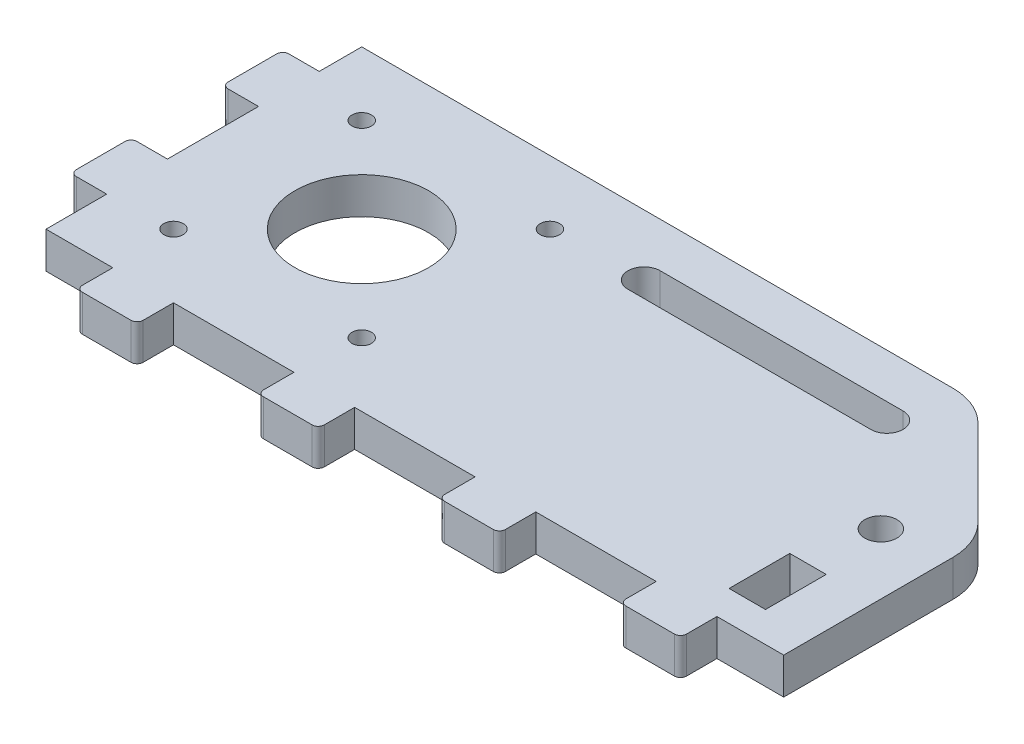
from build123d import *

# Parameters (mm, degrees)
SKETCH1_W               = 121.5
SKETCH1_H               = 52
BOSS_EXTRUDE1_DEPTH     = 6
CHAMFER1_SIZE           = 20
M5_CLEARANCE_HOLE1_D    = 5.3
CUT_EXTRUDE4_DEPTH      = 7
M3_CLEARANCE_HOLE1_D    = 3.2
SKETCH6_R               = 11
CUT_EXTRUDE3_DEPTH      = 7
SKETCH234_W             = 10
SKETCH234_H             = 6
BOSS_EXTRUDE234_DEPTH   = 6
FILLET134_R             = 1
SKETCH2341_W            = 10
SKETCH2341_H            = 6
BOSS_EXTRUDE2341_DEPTH  = 6
FILLET1341_R            = 1
SKETCH2342_W            = 10
SKETCH2342_H            = 6
BOSS_EXTRUDE2342_DEPTH  = 6
FILLET1342_R            = 1
SKETCH2343_W            = 10
SKETCH2343_H            = 6
BOSS_EXTRUDE2343_DEPTH  = 6
FILLET1343_R            = 1
SKETCH2345_W            = 10
SKETCH2345_H            = 6
BOSS_EXTRUDE2345_DEPTH  = 6
FILLET1345_R            = 1
SKETCH2346_W            = 10
SKETCH2346_H            = 6
BOSS_EXTRUDE2346_DEPTH  = 6
FILLET1346_R            = 1
FILLET1347_R            = 10
SKETCH62_W              = 10
SKETCH62_H              = 6
CUT_EXTRUDE1_DEPTH      = 4
CUT_EXTRUDE1_DEPTH_BACK = 4


with BuildPart() as part:
    # Sketch1 → Boss-Extrude1 (new body)
    with BuildSketch(Plane(origin=(0, 0, 0), x_dir=(1, 0, 0), z_dir=(0, 1, 0))):
        with Locations((60.75, 26)):
            Rectangle(SKETCH1_W, SKETCH1_H)
    extrude(amount=BOSS_EXTRUDE1_DEPTH)

    # Chamfer1
    chamfer1_edges = [part.edges().sort_by_distance(p)[0] for p in [
        (121.5, 3, -52),
    ]]
    chamfer(chamfer1_edges, length=CHAMFER1_SIZE)

    # M5 Clearance Hole1 (through all)
    with Locations(Plane(origin=(0, 6, 0), x_dir=(1, 0, 0), z_dir=(0, 1, 0))):
        with Locations((111.5, 26)):
            Hole(M5_CLEARANCE_HOLE1_D / 2)

    # Sketch7 → Cut-Extrude4 (cut, through all)
    with BuildSketch(Plane(origin=(0, 6, 0), x_dir=(1, 0, 0), z_dir=(0, 1, 0))):
        with BuildLine():
            Line((56.5, 44.65), (96.5, 44.65))
            ThreePointArc((96.5, 44.65), (99.15, 42), (96.5, 39.35))
            Line((96.5, 39.35), (56.5, 39.35))
            ThreePointArc((56.5, 39.35), (53.85, 42), (56.5, 44.65))
        make_face()
    extrude(amount=-CUT_EXTRUDE4_DEPTH, mode=Mode.SUBTRACT)

    # M3 Clearance Hole1 (through all)
    with Locations(Plane(origin=(26, 0, -26), x_dir=(0, 0, 1), z_dir=(0, -1, 0))):
        with Locations((15.5, -15.5), (-15.5, -15.5), (-15.5, 15.5), (15.5, 15.5)):
            Hole(M3_CLEARANCE_HOLE1_D / 2)

    # Sketch6 → Cut-Extrude3 (cut, through all)
    with BuildSketch(Plane(origin=(26, 0, -26), x_dir=(0, 0, -1), z_dir=(0, -1, 0))):
        Circle(SKETCH6_R)
    extrude(amount=-CUT_EXTRUDE3_DEPTH, mode=Mode.SUBTRACT)

    # Sketch234 → Boss-Extrude234 (add)
    with BuildSketch(Plane(origin=(16.767778608, 6, 0), x_dir=(-1, 0, 0), z_dir=(0, 0, 1))):
        with Locations((0.767778608, 3)):
            Rectangle(SKETCH234_W, SKETCH234_H)
    extrude(amount=BOSS_EXTRUDE234_DEPTH)

    # Fillet134
    fillet134_edges = [part.edges().sort_by_distance(p)[0] for p in [
        (21, 3, 6),
        (11, 3, 6),
    ]]
    fillet(fillet134_edges, radius=FILLET134_R)

    # Sketch2341 → Boss-Extrude2341 (add)
    with BuildSketch(Plane(origin=(46.601111941, 6, 0), x_dir=(-1, 0, 0), z_dir=(0, 0, 1))):
        with Locations((0.767778608, 3)):
            Rectangle(SKETCH2341_W, SKETCH2341_H)
    extrude(amount=BOSS_EXTRUDE2341_DEPTH)

    # Fillet1341
    fillet1341_edges = [part.edges().sort_by_distance(p)[0] for p in [
        (40.833333333, 3, 6),
        (50.833333333, 3, 6),
    ]]
    fillet(fillet1341_edges, radius=FILLET1341_R)

    # Sketch2342 → Boss-Extrude2342 (add)
    with BuildSketch(Plane(origin=(76.434445274, 6, 0), x_dir=(-1, 0, 0), z_dir=(0, 0, 1))):
        with Locations((0.767778608, 3)):
            Rectangle(SKETCH2342_W, SKETCH2342_H)
    extrude(amount=BOSS_EXTRUDE2342_DEPTH)

    # Fillet1342
    fillet1342_edges = [part.edges().sort_by_distance(p)[0] for p in [
        (70.666666667, 3, 6),
        (80.666666667, 3, 6),
    ]]
    fillet(fillet1342_edges, radius=FILLET1342_R)

    # Sketch2343 → Boss-Extrude2343 (add)
    with BuildSketch(Plane(origin=(106.267778608, 6, 0), x_dir=(-1, 0, 0), z_dir=(0, 0, 1))):
        with Locations((0.767778608, 3)):
            Rectangle(SKETCH2343_W, SKETCH2343_H)
    extrude(amount=BOSS_EXTRUDE2343_DEPTH)

    # Fillet1343
    fillet1343_edges = [part.edges().sort_by_distance(p)[0] for p in [
        (100.5, 3, 6),
        (110.5, 3, 6),
    ]]
    fillet(fillet1343_edges, radius=FILLET1343_R)

    # Sketch2345 → Boss-Extrude2345 (add)
    with BuildSketch(Plane(origin=(0, 0, -15.767778608), x_dir=(0, 0, 1), z_dir=(-1, 0, 0))):
        with Locations((0.767778608, 3)):
            Rectangle(SKETCH2345_W, SKETCH2345_H)
    extrude(amount=BOSS_EXTRUDE2345_DEPTH)

    # Fillet1345
    fillet1345_edges = [part.edges().sort_by_distance(p)[0] for p in [
        (-6, 3, -20),
        (-6, 3, -10),
    ]]
    fillet(fillet1345_edges, radius=FILLET1345_R)

    # Sketch2346 → Boss-Extrude2346 (add)
    with BuildSketch(Plane(origin=(0, 6, -39.232221392), x_dir=(0, 0, -1), z_dir=(-1, 0, 0))):
        with Locations((0.767778608, 3)):
            Rectangle(SKETCH2346_W, SKETCH2346_H)
    extrude(amount=BOSS_EXTRUDE2346_DEPTH)

    # Fillet1346
    fillet1346_edges = [part.edges().sort_by_distance(p)[0] for p in [
        (-6, 3, -45),
        (-6, 3, -35),
    ]]
    fillet(fillet1346_edges, radius=FILLET1346_R)

    # Fillet1347
    fillet1347_edges = [part.edges().sort_by_distance(p)[0] for p in [
        (101.5, 3, -52),
        (121.5, 3, -32),
    ]]
    fillet(fillet1347_edges, radius=FILLET1347_R)

    # Sketch62 → Cut-Extrude1 (cut, two sides)
    with BuildSketch(Plane(origin=(66.5, 3, -10.767778608), x_dir=(0, 0, 1), z_dir=(0, -1, 0))) as cut_extrude1_sk:
        with Locations((0.767778608, -44)):
            Rectangle(SKETCH62_W, SKETCH62_H)
    extrude(amount=CUT_EXTRUDE1_DEPTH, mode=Mode.SUBTRACT)
    extrude(cut_extrude1_sk.sketch, amount=-CUT_EXTRUDE1_DEPTH_BACK, mode=Mode.SUBTRACT)


solid = part.part
